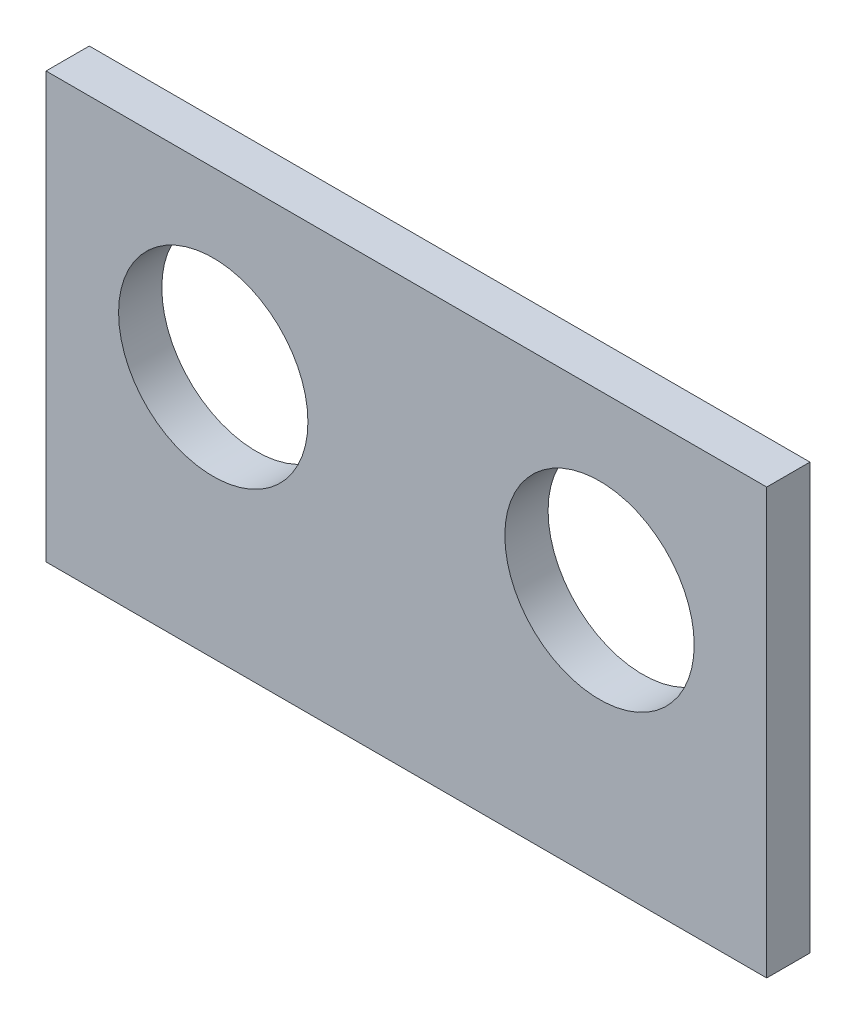
from build123d import *

# Parameters (mm, degrees)
SKETCH1_W           = 25
SKETCH1_H           = 14.75
BOSS_EXTRUDE1_DEPTH = 1.5
SKETCH3_R           = 3.284298871
CUT_EXTRUDE1_DEPTH  = 10


with BuildPart() as part:
    # Sketch1 → Boss-Extrude1 (new body)
    with BuildSketch(Plane.XY):
        Rectangle(SKETCH1_W, SKETCH1_H)
    extrude(amount=BOSS_EXTRUDE1_DEPTH)

    # Sketch3 → Cut-Extrude1 (cut)
    with BuildSketch(Plane(origin=(0, 0, 0), x_dir=(-1, 0, 0), z_dir=(0, 0, -1))):
        with Locations((-6.7, 1.375)):
            Circle(SKETCH3_R)
        with Locations((6.7, 1.375)):
            Circle(SKETCH3_R)
    extrude(amount=-CUT_EXTRUDE1_DEPTH, mode=Mode.SUBTRACT)


solid = part.part
